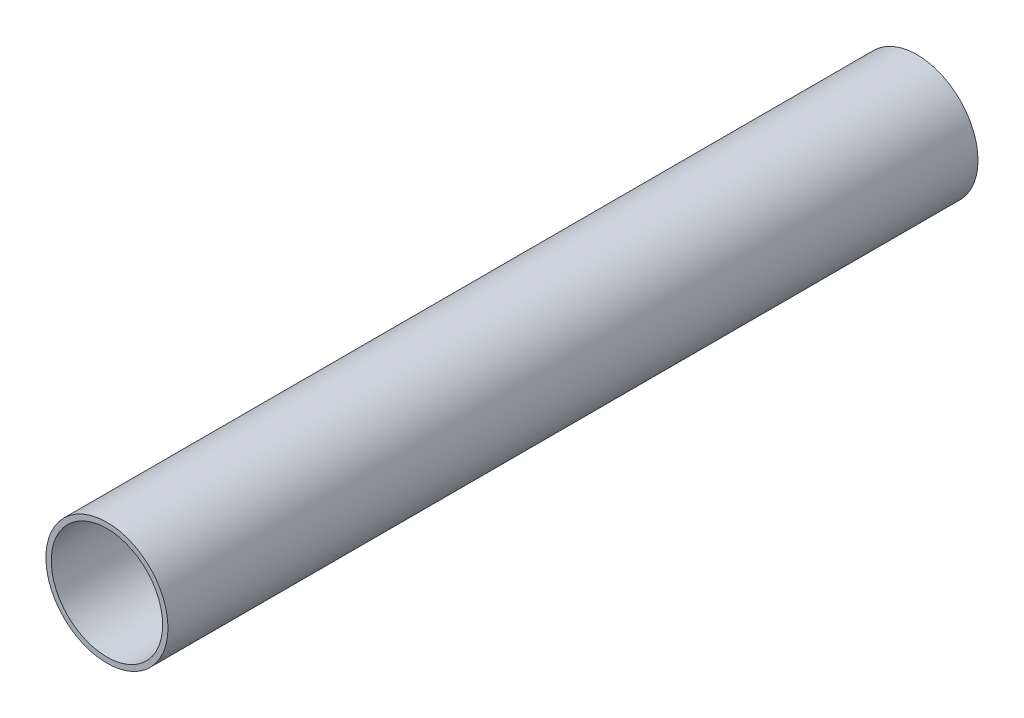
from build123d import *

# Parameters (mm, degrees)
SKETCH1_R           = 30.15
SKETCH1_R_2         = 27.5
BOSS_EXTRUDE1_DEPTH = 400


with BuildPart() as part:
    # Sketch1 → Boss-Extrude1 (new body)
    with BuildSketch(Plane.XY):
        Circle(SKETCH1_R)
        Circle(SKETCH1_R_2, mode=Mode.SUBTRACT)
    extrude(amount=BOSS_EXTRUDE1_DEPTH)


solid = part.part
